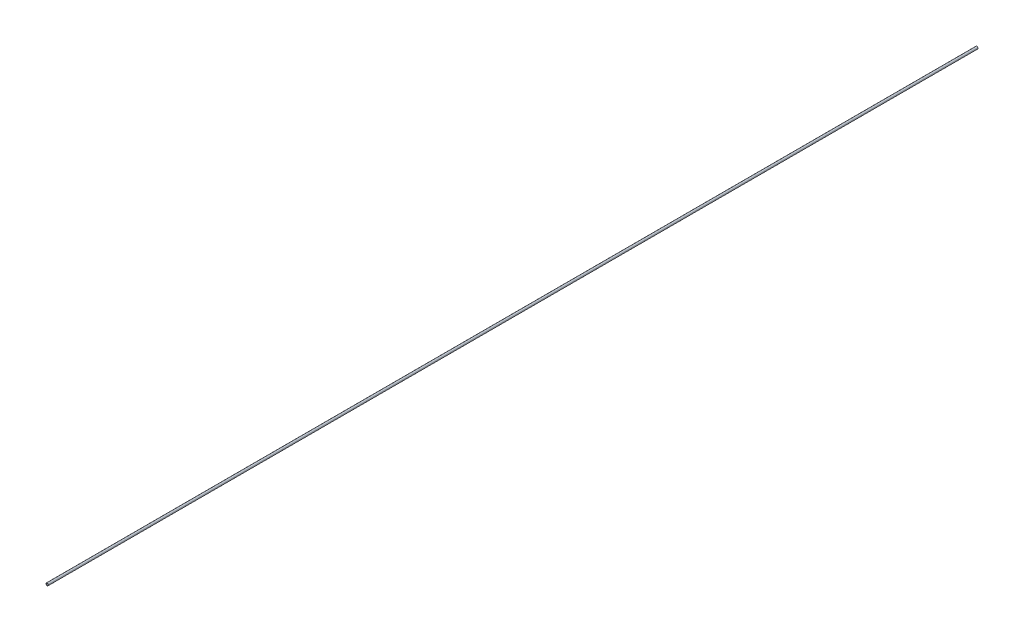
from build123d import *

# Parameters (mm, degrees)
SKETCH1_R           = 2.5
SKETCH1_R_2         = 1.6
BOSS_EXTRUDE1_DEPTH = 1000
SKETCH2_R           = 2.5
SKETCH2_R_2         = 1.6
BOSS_EXTRUDE2_DEPTH = 500
SKETCH3_R           = 2.5
SKETCH3_R_2         = 1.6
BOSS_EXTRUDE3_DEPTH = 500


with BuildPart() as part:
    # Sketch1 → Boss-Extrude1 (new body)
    with BuildSketch(Plane.XY):
        Circle(SKETCH1_R)
        Circle(SKETCH1_R_2, mode=Mode.SUBTRACT)
    extrude(amount=BOSS_EXTRUDE1_DEPTH)

    # Sketch2 → Boss-Extrude2 (add)
    with BuildSketch(Plane.XY.offset(1000)):
        Circle(SKETCH2_R)
        Circle(SKETCH2_R_2, mode=Mode.SUBTRACT)
    extrude(amount=BOSS_EXTRUDE2_DEPTH)

    # Sketch3 → Boss-Extrude3 (add)
    with BuildSketch(Plane.XY.offset(1500)):
        Circle(SKETCH3_R)
        Circle(SKETCH3_R_2, mode=Mode.SUBTRACT)
    extrude(amount=BOSS_EXTRUDE3_DEPTH)


solid = part.part
